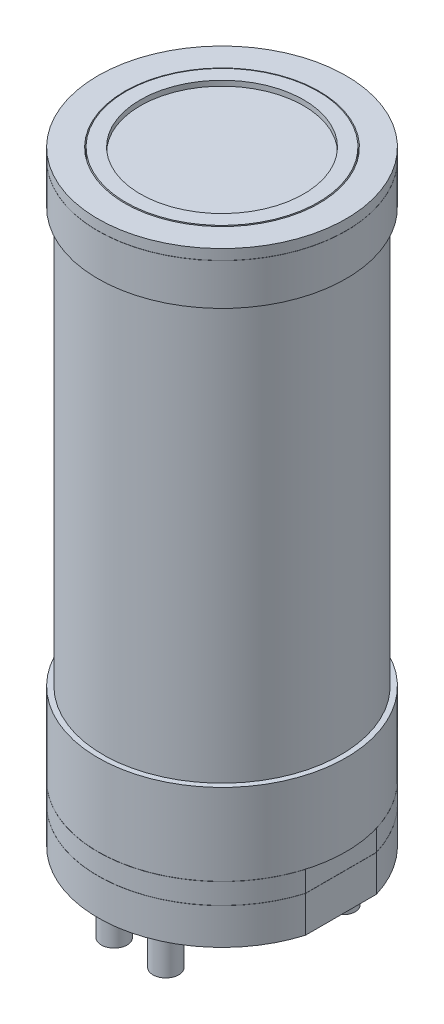
from build123d import *

# Parameters (mm, degrees)
SKETCH2_W           = 59.055
SKETCH2_H           = 9.525
SKETCH2_W_2         = 8.89
SKETCH2_H_2         = 3.175
SKETCH6_W           = 3.175
SKETCH6_H           = 35.025
CUT_EXTRUDE1_DEPTH  = 40
SKETCH9_R           = 3.96875
BOSS_EXTRUDE1_DEPTH = 6
SKETCH10_R          = 7.14375
SKETCH10_R_2        = 7.9375
BOSS_EXTRUDE2_DEPTH = 25.4


with BuildPart() as part:
    # Sketch2 → Revolve1 (revolve)
    with BuildSketch(Plane.XY):
        Polygon((76.2, -25.5), (76.2, -0.1), (66.675, -0.1), (66.675, -330.3), (76.2, -330.3), (76.2, -280.3), (73.025, -280.3), (73.025, -25.5), align=None)
        Polygon((66.04, 0), (76.2, 0), (76.2, 6.35), (59.69, 6.35), (59.69, -6.35), (50.165, -6.35), (50.165, -12.7), (66.04, -12.7), align=None)
        Polygon((66.04, -324.05), (59.69, -324.05), (59.69, -355.8), (66.04, -355.8), (66.04, -343.1), (76.2, -343.1), (76.2, -330.4), (66.04, -330.4), align=None)
        Polygon((76.2, -343.2), (66.675, -343.2), (66.675, -355.9), (0, -355.9), (0, -365.425), (76.2, -365.425), align=None)
        with Locations((29.5275, -1.4875)):
            Rectangle(SKETCH2_W, SKETCH2_H)
        with Locations((54.61, 4.9625)):
            Rectangle(SKETCH2_W_2, SKETCH2_H_2)
    revolve(axis=Axis((0, 3.275, 0), (0, -1, 0)))

    # Sketch6 → Cut-Extrude1 (cut, symmetric)
    with BuildSketch(Plane.XY):
        with Locations((-74.6125, -347.9125)):
            Rectangle(SKETCH6_W, SKETCH6_H)
        with Locations((74.6125, -347.9125)):
            Rectangle(SKETCH6_W, SKETCH6_H)
    extrude(amount=CUT_EXTRUDE1_DEPTH, both=True, mode=Mode.SUBTRACT)

    # Sketch9 → Boss-Extrude1 (add)
    with BuildSketch(Plane.XZ.offset(365.425)):
        with Locations((-15.875, 50.349067488)):
            Circle(SKETCH9_R)
        with Locations((15.875, 50.349067488)):
            Circle(SKETCH9_R)
        with Locations((0, -52.792463684)):
            Circle(SKETCH9_R)
        Polygon((-33.205463081, -44.473659067), (-29.081017096, -37.329909067), (-33.205463081, -30.186159067), (-41.454355052, -30.186159067), (-45.578801038, -37.329909067), (-41.454355052, -44.473659067), align=None)
        Polygon((41.454355052, -44.473659067), (45.578801038, -37.329909067), (41.454355052, -30.186159067), (33.205463081, -30.186159067), (29.081017096, -37.329909067), (33.205463081, -44.473659067), align=None)
    extrude(amount=BOSS_EXTRUDE1_DEPTH)

    # Sketch10 → Boss-Extrude2 (add)
    with BuildSketch(Plane.XZ.offset(371.425)):
        with Locations((-37.329909067, -37.329909067)):
            Circle(SKETCH10_R)
        with Locations((37.329909067, -37.329909067)):
            Circle(SKETCH10_R)
        with Locations((-15.875, 50.349067488)):
            Circle(SKETCH10_R_2)
        with Locations((15.875, 50.349067488)):
            Circle(SKETCH10_R_2)
        with Locations((0, -52.792463684)):
            Circle(SKETCH10_R_2)
    extrude(amount=BOSS_EXTRUDE2_DEPTH)


solid = part.part
